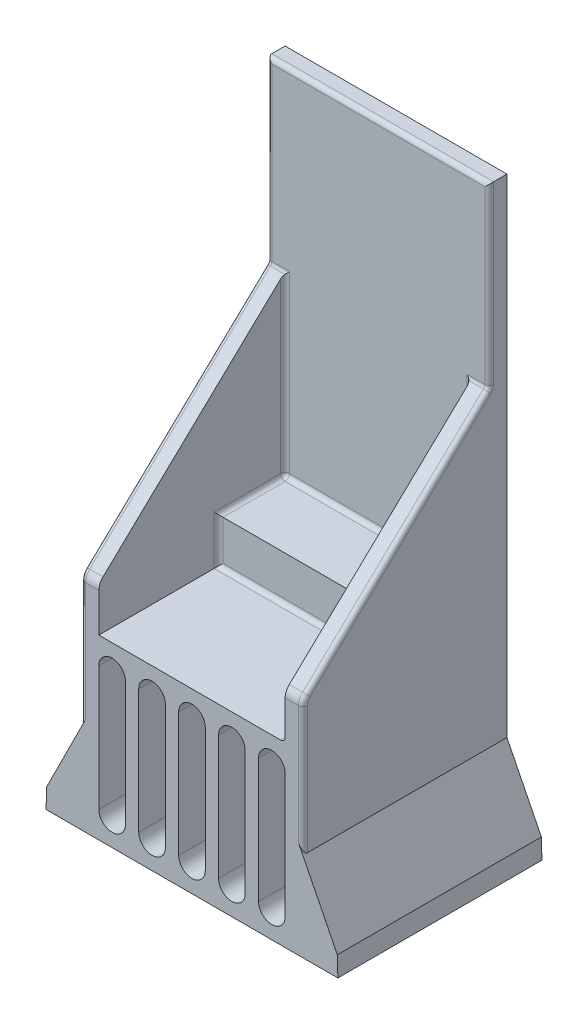
from build123d import *

# Parameters (mm, degrees)
SKETCH_1_W             = 50
SKETCH_1_H             = 46
EXTRUDE_1_DEPTH        = 40
EXTRUDE_2_DEPTH        = 10
SKETCH_8_W             = 42
SKETCH_8_H             = 10
EXTRUDE_5_DEPTH        = 15
SKETCH_3_W             = 50
SKETCH_3_H             = 4
EXTRUDE_3_DEPTH        = 80
SKETCH_4_W             = 70
SKETCH_4_H             = 46
SKETCH_5_W             = 50
SKETCH_5_H             = 46
EXTRUDE_4_DEPTH        = 4
FILLET_2_R             = 3
CHAMFER_1_SIZE2        = 2.113879869
CHAMFER_1_SIZE         = 5
CHAMFER_1_EDGE_2_SIZE2 = 5
CHAMFER_1_EDGE_2_SIZE  = 2.113879869
FILLET_4_R             = 1
CUT_EXTRUDE_1_DEPTH    = 47.0000001
FILLET_5_R             = 1


with BuildPart() as part:
    # 草图1 → 凸台-拉伸1 (new body)
    with BuildSketch(Plane(origin=(0, 0, 0), x_dir=(1, 0, 0), z_dir=(0, 1, 0))):
        with Locations((0, 2)):
            Rectangle(SKETCH_1_W, SKETCH_1_H)
    extrude(amount=EXTRUDE_1_DEPTH)

    # 草图2 → 凸台-拉伸2 (add)
    with BuildSketch(Plane(origin=(0, 40, 0), x_dir=(1, 0, 0), z_dir=(0, 1, 0))):
        Polygon((-25, 25), (-25, -21), (-21, -21), (-21, 21), (21, 21), (21, -21), (25, -21), (25, 25), align=None)
    extrude(amount=EXTRUDE_2_DEPTH)

    # 草图8 → 凸台-拉伸5 (add)
    with BuildSketch(Plane.XY.offset(-21)):
        with Locations((0, 45)):
            Rectangle(SKETCH_8_W, SKETCH_8_H)
    extrude(amount=EXTRUDE_5_DEPTH)

    # 草图3 → 凸台-拉伸3 (add)
    with BuildSketch(Plane(origin=(0, 50, 0), x_dir=(1, 0, 0), z_dir=(0, 1, 0))):
        with Locations((0, 23)):
            Rectangle(SKETCH_3_W, SKETCH_3_H)
    extrude(amount=EXTRUDE_3_DEPTH)

    # 草图4 → 放样2 section 0
    with BuildSketch(Plane.XZ):
        with Locations((0, -2)):
            Rectangle(SKETCH_4_W, SKETCH_4_H)
    # 草图5 → 放样2 section 1
    with BuildSketch(Plane(origin=(0, 20, 0), x_dir=(1, 0, 0), z_dir=(0, 1, 0))):
        with Locations((0, 2)):
            Rectangle(SKETCH_5_W, SKETCH_5_H)
    loft()

    # 草图6 → 凸台-拉伸4 (add)
    with BuildSketch(Plane.ZY.offset(25)):
        Polygon((-21, 90), (21, 50), (-21, 50), align=None)
    extrude_4 = extrude(amount=-EXTRUDE_4_DEPTH)

    # 镜向2: 凸台-拉伸4 across plane
    add(extrude_4.mirror(Plane(origin=(0, 0, 0), x_dir=(0, 0, 1), z_dir=(1, 0, 0))))

    # 圆角2
    fillet_2_edges = [part.edges().sort_by_distance(p)[0] for p in [
        (23, 50, 21),
        (-23, 50, 21),
    ]]
    fillet(fillet_2_edges, radius=FILLET_2_R)

    # 倒角1
    chamfer_1_edges = [part.edges().sort_by_distance(p)[0] for p in [
        (35, 0, -2),
    ]]
    chamfer(chamfer_1_edges, length=CHAMFER_1_SIZE, length2=CHAMFER_1_SIZE2)

    # 倒角1 edge 2
    chamfer_1_edge_2_edges = [part.edges().sort_by_distance(p)[0] for p in [
        (-35, 0, -2),
    ]]
    chamfer(chamfer_1_edge_2_edges, length=CHAMFER_1_EDGE_2_SIZE, length2=CHAMFER_1_EDGE_2_SIZE2)

    # 圆角4
    fillet_4_edges = [part.edges().sort_by_distance(p)[0] for p in [
        (21, 40, 7.5),
    ]]
    fillet(fillet_4_edges, radius=FILLET_4_R)

    # 草图7 → 切除-拉伸1 (cut, through all)
    with BuildSketch(Plane.XY.offset(21)):
        with BuildLine():
            Line((-21, 34), (-21, 6))
            ThreePointArc((-21, 6), (-18, 3), (-15, 6))
            Line((-15, 6), (-15, 34))
            ThreePointArc((-15, 34), (-18, 37), (-21, 34))
        make_face()
        with BuildLine():
            Line((-12, 34), (-12, 6))
            ThreePointArc((-12, 6), (-9, 3), (-6, 6))
            Line((-6, 6), (-6, 34))
            ThreePointArc((-6, 34), (-9, 37), (-12, 34))
        make_face()
        with BuildLine():
            Line((-3, 34), (-3, 6))
            ThreePointArc((-3, 6), (0, 3), (3, 6))
            Line((3, 6), (3, 34))
            ThreePointArc((3, 34), (0, 37), (-3, 34))
        make_face()
        with BuildLine():
            Line((6, 34), (6, 6))
            ThreePointArc((6, 6), (9, 3), (12, 6))
            Line((12, 6), (12, 34))
            ThreePointArc((12, 34), (9, 37), (6, 34))
        make_face()
        with BuildLine():
            Line((15, 34), (15, 6))
            ThreePointArc((15, 6), (18, 3), (21, 6))
            Line((21, 6), (21, 34))
            ThreePointArc((21, 34), (18, 37), (15, 34))
        make_face()
    extrude(amount=-CUT_EXTRUDE_1_DEPTH, mode=Mode.SUBTRACT)

    # 圆角5
    fillet_5_edges = [part.edges().sort_by_distance(p)[0] for p in [
        (-25, 34.357142857, 21),
        (25, 34.357142857, 21),
        (-25, 49.89604361, 20.75743509),
        (25, 49.89604361, 20.75743509),
        (-25, 70.443349754, -0.465517241),
        (25, 70.443349754, -0.465517241),
        (-0.5, 40, -6),
        (20.707106781, 40.292893219, -6),
        (21, 70, -21),
        (0, 50, -21),
        (-21, 70, -21),
        (-23, 90, -21),
        (-25, 110, -21),
        (0, 130, -21),
        (25, 110, -21),
        (23, 90, -21),
        (-21, 50, -13.5),
        (-21, 45, -6),
        (21, 45.5, -6),
    ]]
    fillet(fillet_5_edges, radius=FILLET_5_R)


solid = part.part
